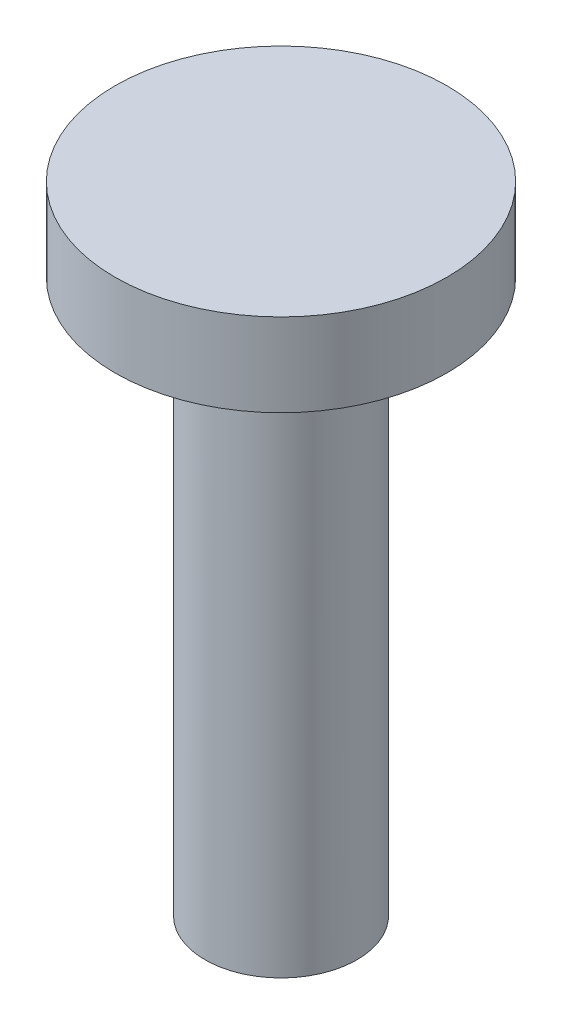
from build123d import *

# Parameters (mm, degrees)
SKETCH1_R           = 10
BOSS_EXTRUDE1_DEPTH = 66.666666667
SCALE_1_SCALE       = 0.3
SKETCH_1_R          = 6
EXTRUDE_1_DEPTH     = 3
SKETCH_2_R          = 3
SKETCH_2_R_2        = 2.75
CUT_EXTRUDE_1_DEPTH = 20


with BuildPart() as part:
    # Sketch1 → Boss-Extrude1 (new body)
    with BuildSketch(Plane(origin=(0, 0, 0), x_dir=(1, 0, 0), z_dir=(0, 1, 0))):
        Circle(SKETCH1_R)
    extrude(amount=BOSS_EXTRUDE1_DEPTH)


with BuildPart() as part_1:
    # 축척1: scaled about (0, 33.333333333, 0)
    add(part.part.scale(SCALE_1_SCALE).moved(Location((0, 23.333333333, 0))))

    # 스케치1 → 보스-돌출1 (add)
    with BuildSketch(Plane(origin=(0, 43.333333333, 0), x_dir=(1, 0, 0), z_dir=(0, 1, 0))):
        Circle(SKETCH_1_R)
    extrude(amount=EXTRUDE_1_DEPTH)

    # 스케치2 → 컷-돌출1 (cut)
    with BuildSketch(Plane.XZ.offset(-23.333333333)):
        Circle(SKETCH_2_R)
        Circle(SKETCH_2_R_2, mode=Mode.SUBTRACT)
    extrude(amount=-CUT_EXTRUDE_1_DEPTH, mode=Mode.SUBTRACT)


solid = part_1.part
